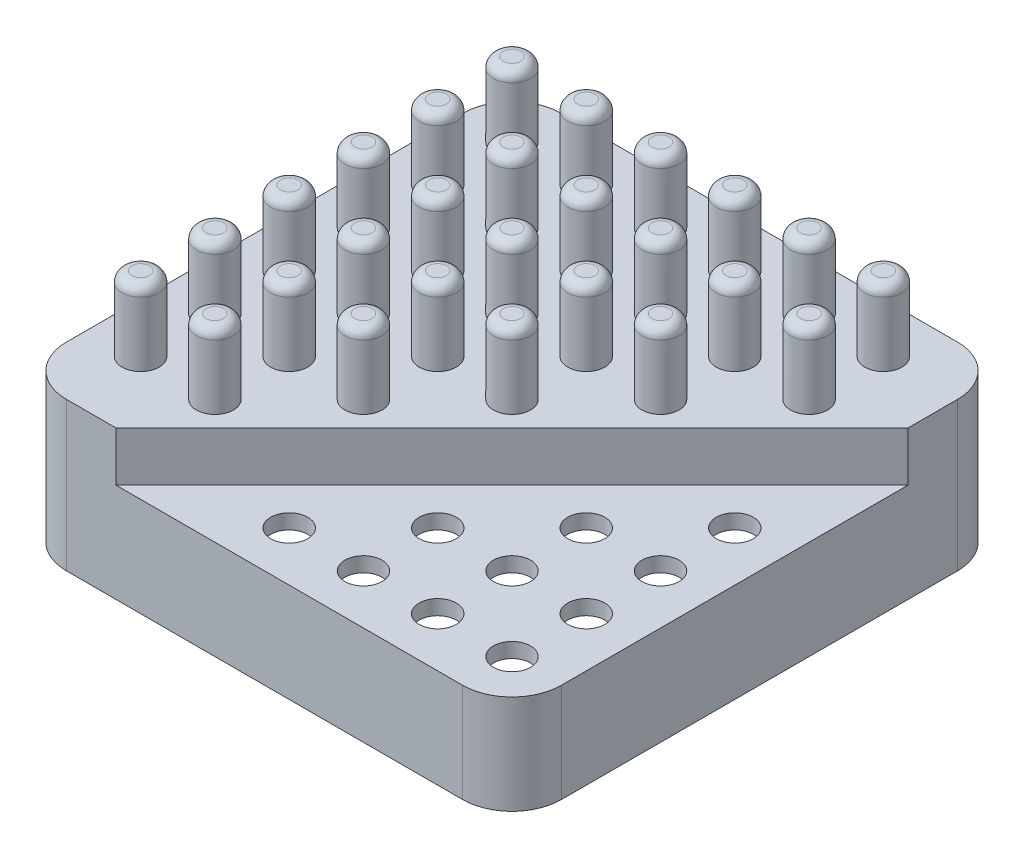
from build123d import *

# Parameters (mm, degrees)
BOSS_EXTRUDE1_DEPTH    = 30
CUT_EXTRUDE1_DEPTH     = 10
SHELL1_T               = -3
SKETCH7_R              = 3.75
CUT_EXTRUDE2_DEPTH     = 10
LPATTERN1_COUNT        = 4
LPATTERN1_PITCH        = 15
LPATTERN1_COUNT_DIR2   = 4
LPATTERN1_PITCH_DIR2   = 15
SKETCH8_R              = 3.75
BOSS_EXTRUDE5_DEPTH    = 15
FILLET1_R              = 2
LPATTERN5_COUNT        = 6
LPATTERN5_PITCH        = 15
LPATTERN5_COUNT_DIR2   = 6
LPATTERN5_PITCH_DIR2   = 15
FILLET1_OF_LPATTERN5_R = 2


with BuildPart() as part:
    # Sketch1 → Boss-Extrude1 (new body)
    with BuildSketch(Plane(origin=(0, 0, 0), x_dir=(1, 0, 0), z_dir=(0, 1, 0))):
        with BuildLine():
            Line((10, 0), (90, 0))
            ThreePointArc((90, 0), (97.071067812, 2.928932188), (100, 10))
            Line((100, 10), (100, 90))
            ThreePointArc((100, 90), (97.071067812, 97.071067812), (90, 100))
            Line((90, 100), (10, 100))
            ThreePointArc((10, 100), (2.928932188, 97.071067812), (0, 90))
            Line((0, 90), (0, 10))
            ThreePointArc((0, 10), (2.928932188, 2.928932188), (10, 0))
        make_face()
    extrude(amount=BOSS_EXTRUDE1_DEPTH)

    # Sketch2 → Cut-Extrude1 (cut)
    with BuildSketch(Plane(origin=(0, 30, 0), x_dir=(1, 0, 0), z_dir=(0, 1, 0))):
        with BuildLine():
            Line((20, 0), (100, 80))
            Line((100, 80), (100, 10))
            ThreePointArc((100, 10), (97.071067812, 2.928932188), (90, 0))
            Line((90, 0), (20, 0))
        make_face()
    extrude(amount=-CUT_EXTRUDE1_DEPTH, mode=Mode.SUBTRACT)

    # Shell1
    shell1_openings = [part.faces().sort_by_distance(p)[0] for p in [
        (50, 0, -50),
    ]]
    offset(amount=SHELL1_T, openings=shell1_openings, kind=Kind.INTERSECTION)

    # Sketch7 → Cut-Extrude2 (cut)
    with BuildSketch(Plane(origin=(0, 20, 0), x_dir=(1, 0, 0), z_dir=(0, 1, 0))):
        with Locations((90, 10)):
            Circle(SKETCH7_R)
    cut_extrude2 = extrude(amount=-CUT_EXTRUDE2_DEPTH, mode=Mode.SUBTRACT)

    # LPattern1: Cut-Extrude2 4 × 4, 6 skipped
    with Locations(*[(-j * LPATTERN1_PITCH_DIR2, 0, -i * LPATTERN1_PITCH) for i in range(LPATTERN1_COUNT) for j in range(LPATTERN1_COUNT_DIR2) if (i, j) not in ((0, 0), (1, 3), (2, 2), (2, 3), (3, 1), (3, 2), (3, 3))]):
        add(cut_extrude2, mode=Mode.SUBTRACT)

    # Sketch8 → Boss-Extrude5 (add)
    with BuildSketch(Plane(origin=(0, 30, 0), x_dir=(1, 0, 0), z_dir=(0, 1, 0))):
        with Locations((10, 90)):
            Circle(SKETCH8_R)
    boss_extrude5 = extrude(amount=BOSS_EXTRUDE5_DEPTH)

    # Fillet1
    fillet1_edges = [part.edges().sort_by_distance(p)[0] for p in [
        (6.25, 45, -90),
    ]]
    fillet(fillet1_edges, radius=FILLET1_R)

    # LPattern5: Boss-Extrude5 6 × 6, 10 skipped
    with Locations(*[(i * LPATTERN5_PITCH, 0, j * LPATTERN5_PITCH_DIR2) for i in range(LPATTERN5_COUNT) for j in range(LPATTERN5_COUNT_DIR2) if (i, j) not in ((0, 0), (2, 5), (3, 4), (3, 5), (4, 3), (4, 4), (4, 5), (5, 2), (5, 3), (5, 4), (5, 5))]):
        add(boss_extrude5)

    # Fillet1 of LPattern5
    fillet1_of_lpattern5_edges = [part.edges().sort_by_distance(p)[0] for p in [
        (6.25, 45, -75),
        (6.25, 45, -60),
        (6.25, 45, -45),
        (6.25, 45, -30),
        (6.25, 45, -15),
        (21.25, 45, -90),
        (21.25, 45, -75),
        (21.25, 45, -60),
        (21.25, 45, -45),
        (21.25, 45, -30),
        (21.25, 45, -15),
        (36.25, 45, -90),
        (36.25, 45, -75),
        (36.25, 45, -60),
        (36.25, 45, -45),
        (36.25, 45, -30),
        (51.25, 45, -90),
        (51.25, 45, -75),
        (51.25, 45, -60),
        (51.25, 45, -45),
        (66.25, 45, -90),
        (66.25, 45, -75),
        (66.25, 45, -60),
        (81.25, 45, -90),
        (81.25, 45, -75),
    ]]
    fillet(fillet1_of_lpattern5_edges, radius=FILLET1_OF_LPATTERN5_R)


solid = part.part
